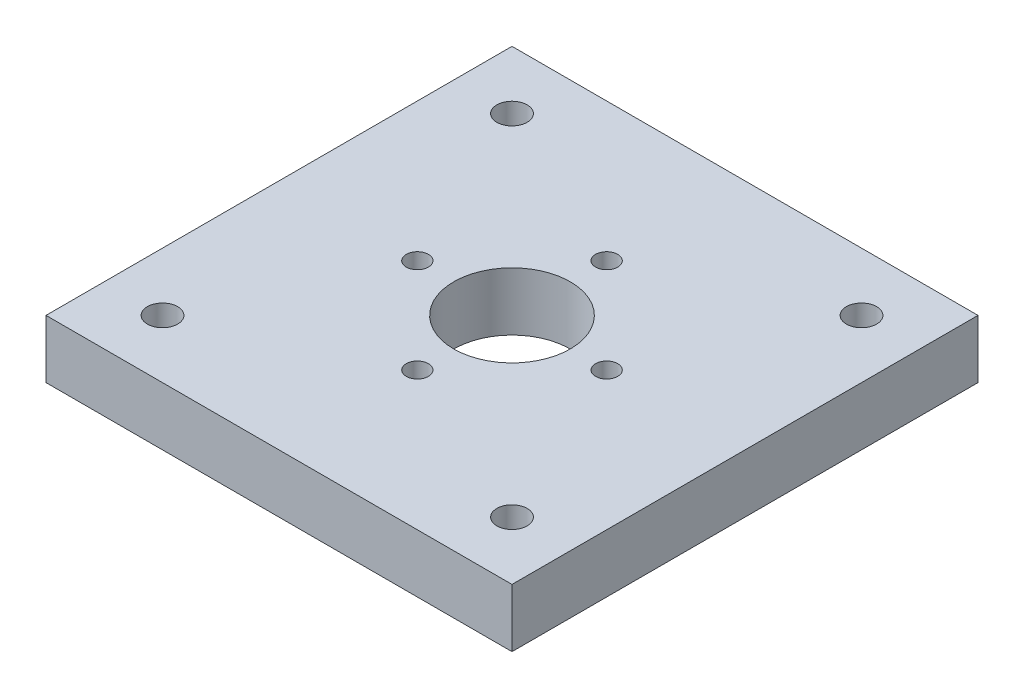
from build123d import *

# Parameters (mm, degrees)
SKETCH1_W           = 4
SKETCH1_H           = 4
SKETCH1_R           = 0.5
SKETCH1_R_2         = 0.095
SKETCH1_R_3         = 0.13
BOSS_EXTRUDE1_DEPTH = 0.5


with BuildPart() as part:
    # Sketch1 → Boss-Extrude1 (new body)
    with BuildSketch(Plane(origin=(0, 0, 0), x_dir=(1, 0, 0), z_dir=(0, 1, 0))):
        Rectangle(SKETCH1_W, SKETCH1_H)
        Circle(SKETCH1_R, mode=Mode.SUBTRACT)
        with Locations((0, 0.8125)):
            Circle(SKETCH1_R_2, mode=Mode.SUBTRACT)
        with Locations((0.8125, 0)):
            Circle(SKETCH1_R_2, mode=Mode.SUBTRACT)
        with Locations((0, -0.8125)):
            Circle(SKETCH1_R_2, mode=Mode.SUBTRACT)
        with Locations((-0.8125, 0)):
            Circle(SKETCH1_R_2, mode=Mode.SUBTRACT)
        with Locations((-1.5, 1.5)):
            Circle(SKETCH1_R_3, mode=Mode.SUBTRACT)
        with Locations((1.5, 1.5)):
            Circle(SKETCH1_R_3, mode=Mode.SUBTRACT)
        with Locations((-1.5, -1.5)):
            Circle(SKETCH1_R_3, mode=Mode.SUBTRACT)
        with Locations((1.5, -1.5)):
            Circle(SKETCH1_R_3, mode=Mode.SUBTRACT)
    extrude(amount=BOSS_EXTRUDE1_DEPTH)


solid = part.part
